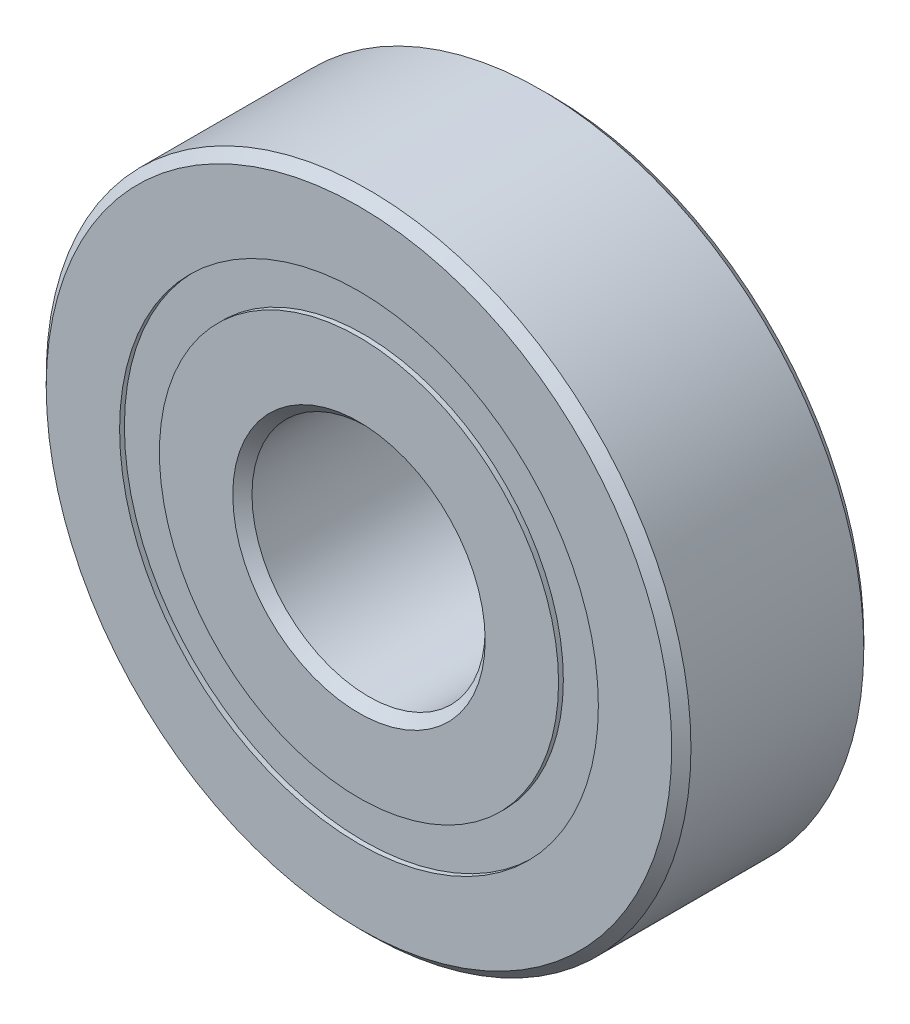
from build123d import *

# Parameters (mm, degrees)
CIRPATTERN1_COUNT = 12
SKETCH5_W         = 3.217347082
SKETCH5_H         = 2.901098902


with BuildPart() as part:
    # Sketch6 → Revolve1 (revolve)
    with BuildSketch(Plane(origin=(0, 0, 0), x_dir=(0, 0, -1), z_dir=(1, 0, 0))):
        with BuildLine():
            Line((-7, 22.8), (-7, 17.450549451))
            Line((-7, 17.450549451), (-3.111111111, 17.450549451))
            ThreePointArc((-3.111111111, 17.450549451), (0, 19.432652918), (3.111111111, 17.450549451))
            Line((3.111111111, 17.450549451), (7, 17.450549451))
            Line((7, 17.450549451), (7, 22.8))
            Line((7, 22.8), (6.3, 23.5))
            Line((6.3, 23.5), (-6.3, 23.5))
            Line((-6.3, 23.5), (-7, 22.8))
        make_face()
        with BuildLine():
            Line((-7, 9.2), (-7, 14.549450549))
            Line((-7, 14.549450549), (-3.111111111, 14.549450549))
            ThreePointArc((-3.111111111, 14.549450549), (0, 12.567347082), (3.111111111, 14.549450549))
            Line((3.111111111, 14.549450549), (7, 14.549450549))
            Line((7, 14.549450549), (7, 9.2))
            Line((7, 9.2), (6.3, 8.5))
            Line((6.3, 8.5), (-6.3, 8.5))
            Line((-6.3, 8.5), (-7, 9.2))
        make_face()
    revolve(axis=Axis((0, 0, 7), (0, 0, -1)))


with BuildPart() as body_2:
    # Sketch4 → Revolve2 (revolve)
    with BuildSketch(Plane(origin=(0, 0, 0), x_dir=(0, 0, -1), z_dir=(1, 0, 0))):
        with BuildLine():
            Line((-3.432652918, 16), (3.432652918, 16))
            ThreePointArc((3.432652918, 16), (0, 19.432652918), (-3.432652918, 16))
        make_face()
    revolve(axis=Axis((0, 16, 3.432652918), (0, 0, -1)))


with BuildPart() as cirpattern1_1:
    # CirPattern1: pattern copy
    add(body_2.part.rotate(Axis((0, 0, -7), (0, 0, 1)), 1 * 360 / CIRPATTERN1_COUNT))


with BuildPart() as cirpattern1_2:
    # CirPattern1: pattern copy
    add(body_2.part.rotate(Axis((0, 0, -7), (0, 0, 1)), 2 * 360 / CIRPATTERN1_COUNT))


with BuildPart() as cirpattern1_3:
    # CirPattern1: pattern copy
    add(body_2.part.rotate(Axis((0, 0, -7), (0, 0, 1)), 3 * 360 / CIRPATTERN1_COUNT))


with BuildPart() as cirpattern1_4:
    # CirPattern1: pattern copy
    add(body_2.part.rotate(Axis((0, 0, -7), (0, 0, 1)), 4 * 360 / CIRPATTERN1_COUNT))


with BuildPart() as cirpattern1_5:
    # CirPattern1: pattern copy
    add(body_2.part.rotate(Axis((0, 0, -7), (0, 0, 1)), 5 * 360 / CIRPATTERN1_COUNT))


with BuildPart() as cirpattern1_6:
    # CirPattern1: pattern copy
    add(body_2.part.rotate(Axis((0, 0, -7), (0, 0, 1)), 6 * 360 / CIRPATTERN1_COUNT))


with BuildPart() as cirpattern1_7:
    # CirPattern1: pattern copy
    add(body_2.part.rotate(Axis((0, 0, -7), (0, 0, 1)), 7 * 360 / CIRPATTERN1_COUNT))


with BuildPart() as cirpattern1_8:
    # CirPattern1: pattern copy
    add(body_2.part.rotate(Axis((0, 0, -7), (0, 0, 1)), 8 * 360 / CIRPATTERN1_COUNT))


with BuildPart() as cirpattern1_9:
    # CirPattern1: pattern copy
    add(body_2.part.rotate(Axis((0, 0, -7), (0, 0, 1)), 9 * 360 / CIRPATTERN1_COUNT))


with BuildPart() as cirpattern1_10:
    # CirPattern1: pattern copy
    add(body_2.part.rotate(Axis((0, 0, -7), (0, 0, 1)), 10 * 360 / CIRPATTERN1_COUNT))


with BuildPart() as cirpattern1_11:
    # CirPattern1: pattern copy
    add(body_2.part.rotate(Axis((0, 0, -7), (0, 0, 1)), 11 * 360 / CIRPATTERN1_COUNT))


with BuildPart() as revolve3_tool:
    # Sketch5 → Revolve3 (revolve)
    with BuildSketch(Plane(origin=(0, 0, 0), x_dir=(0, 0, -1), z_dir=(1, 0, 0))):
        with Locations((-5.041326459, 16)):
            Rectangle(SKETCH5_W, SKETCH5_H)
        with Locations((5.041326459, 16)):
            Rectangle(SKETCH5_W, SKETCH5_H)
    revolve(axis=Axis((0, 0, 7), (0, 0, -1)))


with BuildPart() as part_1:
    add(part.part)


with BuildPart() as part_2:
    # Revolve3: joined with revolve3_tool
    add(part_1.part.fuse(revolve3_tool.part, body_2.part, cirpattern1_1.part, cirpattern1_2.part, cirpattern1_3.part, cirpattern1_4.part, cirpattern1_5.part, cirpattern1_6.part, cirpattern1_7.part, cirpattern1_8.part, cirpattern1_9.part, cirpattern1_10.part, cirpattern1_11.part, tol=0.00001))


solid = part_2.part
